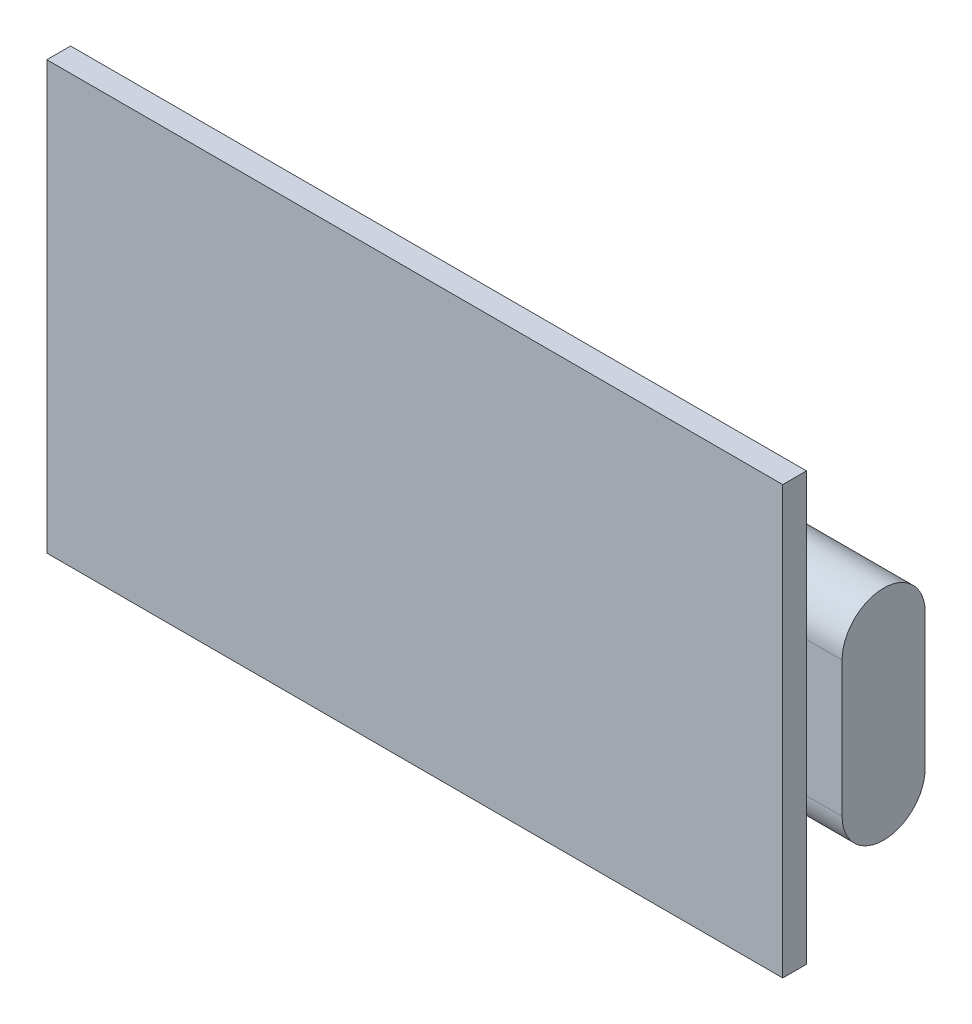
from build123d import *

# Parameters (mm, degrees)
ESBO_O1_W                     = 31
ESBO_O1_H                     = 18
RESSALTO_EXTRUS_O1_DEPTH      = 1
RESSALTO_EXTRUS_O2_DEPTH      = 1.5
RESSALTO_EXTRUS_O2_DEPTH_BACK = 6


with BuildPart() as part:
    # Esboço1 → Ressalto-extrusão1 (new body)
    with BuildSketch(Plane.XY):
        Rectangle(ESBO_O1_W, ESBO_O1_H)
    extrude(amount=RESSALTO_EXTRUS_O1_DEPTH)

    # Esboço2 → Ressalto-extrusão2 (add, two sides)
    with BuildSketch(Plane(origin=(15.5, 0, 0), x_dir=(0, 0, -1), z_dir=(1, 0, 0))) as ressalto_extrus_o2_sk:
        with BuildLine():
            Line((3.5, 2.85), (3.5, -2.85))
            ThreePointArc((3.5, -2.85), (1.75, -4.6), (0, -2.85))
            Line((0, -2.85), (0, 2.85))
            ThreePointArc((0, 2.85), (1.75, 4.6), (3.5, 2.85))
        make_face()
    extrude(amount=RESSALTO_EXTRUS_O2_DEPTH)
    extrude(ressalto_extrus_o2_sk.sketch, amount=-RESSALTO_EXTRUS_O2_DEPTH_BACK)


solid = part.part
